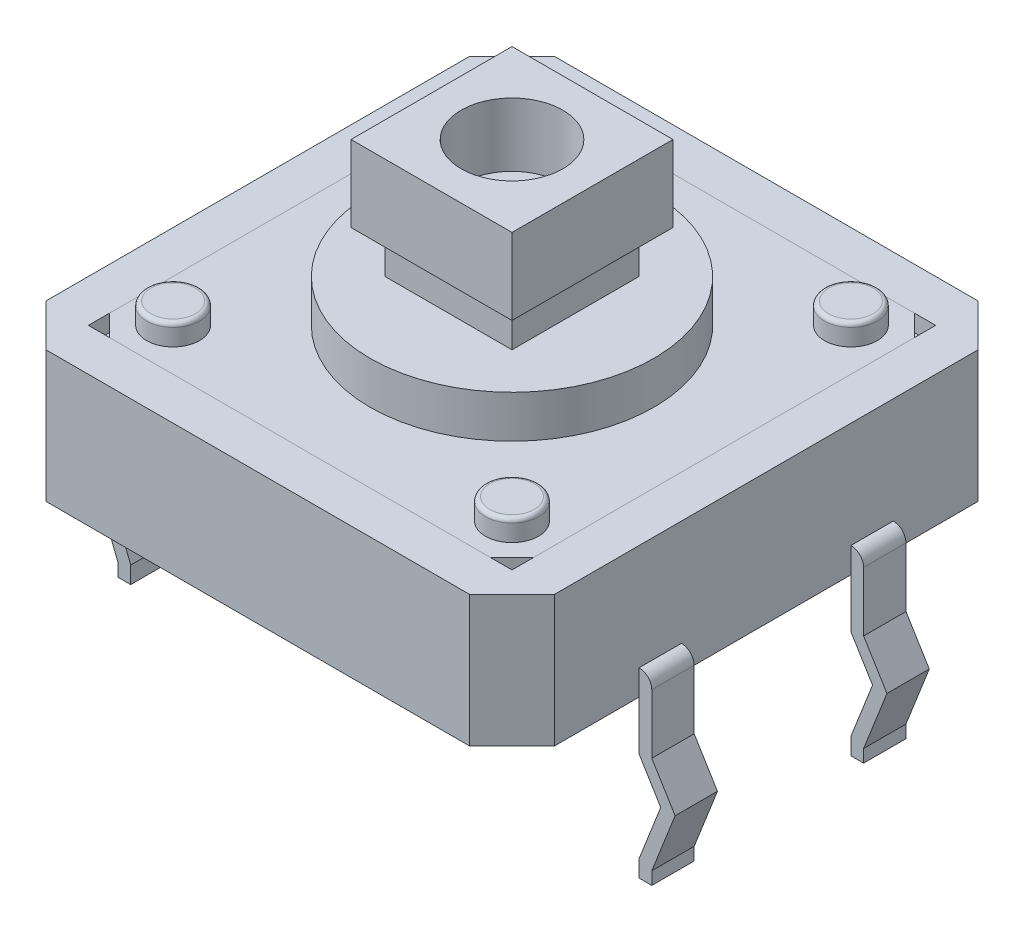
from build123d import *

# Parameters (mm, degrees)
BOSS_EXTRUDE1_DEPTH        = 3.1
SKETCH2_W                  = 10
SKETCH2_H                  = 10
CUT_EXTRUDE1_DEPTH         = 0.4
SKETCH3_R                  = 0.625
BOSS_EXTRUDE2_DEPTH        = 0.9
FILLET1_R                  = 0.1
SKETCH4_R                  = 3.35
BOSS_EXTRUDE3_DEPTH        = 0.4
BOSS_EXTRUDE4_DEPTH        = 3
BOSS_EXTRUDE4_DEPTH_BACK   = 3
BOSS_EXTRUDE4_2_DEPTH      = 3
BOSS_EXTRUDE4_2_DEPTH_BACK = 3
SKETCH6_W                  = 0.85
SKETCH6_H                  = 4
CUT_EXTRUDE2_DEPTH         = 4.6
CUT_EXTRUDE2_DEPTH_BACK    = 4.7
SKETCH7_R                  = 3.35
BOSS_EXTRUDE5_DEPTH        = 1.4
SKETCH8_W                  = 3
SKETCH8_H                  = 3
BOSS_EXTRUDE6_DEPTH        = 1
SKETCH9_W                  = 3.8
SKETCH9_H                  = 3.8
BOSS_EXTRUDE7_DEPTH        = 1.8
SKETCH11_R                 = 1.2
CUT_EXTRUDE3_DEPTH         = 1.5
BOSS_EXTRUDE8_DEPTH        = 0.2


with BuildPart() as part:
    # Sketch1 → Boss-Extrude1 (new body)
    with BuildSketch(Plane(origin=(0, 0, 0), x_dir=(1, 0, 0), z_dir=(0, 1, 0))):
        Polygon((-5, 6), (-6, 5), (-6, -5), (-5, -6), (5, -6), (6, -5), (6, 5), (5, 6), align=None)
    extrude(amount=BOSS_EXTRUDE1_DEPTH)

    # Sketch2 → Cut-Extrude1 (cut)
    with BuildSketch(Plane(origin=(0, 3.1, 0), x_dir=(1, 0, 0), z_dir=(0, 1, 0))):
        Rectangle(SKETCH2_W, SKETCH2_H)
    extrude(amount=-CUT_EXTRUDE1_DEPTH, mode=Mode.SUBTRACT)

    # Sketch3 → Boss-Extrude2 (add)
    with BuildSketch(Plane(origin=(0, 2.7, 0), x_dir=(1, 0, 0), z_dir=(0, 1, 0))):
        with Locations((-4, 4)):
            Circle(SKETCH3_R)
        with Locations((4, 4)):
            Circle(SKETCH3_R)
        with Locations((-4, -4)):
            Circle(SKETCH3_R)
        with Locations((4, -4)):
            Circle(SKETCH3_R)
    extrude(amount=BOSS_EXTRUDE2_DEPTH)

    # Fillet1
    fillet1_edges = [part.edges().sort_by_distance(p)[0] for p in [
        (-4.625, 3.6, -4),
        (3.375, 3.6, -4),
        (-4.625, 3.6, 4),
        (3.375, 3.6, 4),
    ]]
    fillet(fillet1_edges, radius=FILLET1_R)

    # Sketch12 → Boss-Extrude8 (add)
    with BuildSketch(Plane.XZ):
        Polygon((3, 5.5), (3, 3.7), (5.5, 3.7), (5.5, 4.792893219), (4.792893219, 5.5), align=None)
        Polygon((4.792893219, -5.5), (5.5, -4.792893219), (5.5, -3.7), (3, -3.7), (3, -5.5), align=None)
        Polygon((-3, -5.5), (-3, -3.7), (-5.5, -3.7), (-5.5, -4.792893219), (-4.792893219, -5.5), align=None)
        Polygon((-4.792893219, 5.5), (-5.5, 4.792893219), (-5.5, 3.7), (-3, 3.7), (-3, 5.5), align=None)
    extrude(amount=BOSS_EXTRUDE8_DEPTH)


with BuildPart() as body_2:
    # Sketch4 → Boss-Extrude3 (new body)
    with BuildSketch(Plane(origin=(0, 2.7, 0), x_dir=(1, 0, 0), z_dir=(0, 1, 0))):
        Polygon((4.5, -5), (-4.5, -5), (-5, -4.5), (-5, 4.5), (-4.5, 5), (4.5, 5), (5, 4.5), (5, -4.5), align=None)
        Circle(SKETCH4_R, mode=Mode.SUBTRACT)
    extrude(amount=BOSS_EXTRUDE3_DEPTH)


with BuildPart() as body_3:
    # Sketch5 → Boss-Extrude4 (new body, two sides)
    with BuildSketch(Plane.XY) as boss_extrude4_sk:
        with BuildLine():
            Line((6, 0.6), (6, -1.164285714))
            Line((6, -1.164285714), (6.510714286, -2))
            Line((6.510714286, -2), (6, -3.3))
            Line((6, -3.3), (6, -3.7))
            Line((6, -3.7), (6.3, -3.7))
            Line((6.3, -3.7), (6.3, -3.4))
            Line((6.3, -3.4), (6.85, -2))
            Line((6.85, -2), (6.3, -1.1))
            Line((6.3, -1.1), (6.3, 0.3))
            ThreePointArc((6.3, 0.3), (6.212132034, 0.512132034), (6, 0.6))
        make_face()
    extrude(amount=BOSS_EXTRUDE4_DEPTH)
    extrude(boss_extrude4_sk.sketch, amount=-BOSS_EXTRUDE4_DEPTH_BACK)


with BuildPart() as body_4:
    # Sketch5 → Boss-Extrude4 2 (new body, two sides)
    with BuildSketch(Plane.XY) as boss_extrude4_2_sk:
        with BuildLine():
            Line((-6.510714286, -2), (-6, -3.3))
            Line((-6, -3.3), (-6, -3.7))
            Line((-6, -3.7), (-6.3, -3.7))
            Line((-6.3, -3.7), (-6.3, -3.4))
            Line((-6.3, -3.4), (-6.85, -2))
            Line((-6.85, -2), (-6.3, -1.1))
            Line((-6.3, -1.1), (-6.3, 0.3))
            ThreePointArc((-6.3, 0.3), (-6.212132034, 0.512132034), (-6, 0.6))
            Line((-6, 0.6), (-6, -1.164285714))
            Line((-6, -1.164285714), (-6.510714286, -2))
        make_face()
    extrude(amount=BOSS_EXTRUDE4_2_DEPTH)
    extrude(boss_extrude4_2_sk.sketch, amount=-BOSS_EXTRUDE4_2_DEPTH_BACK)


with BuildPart() as cut_extrude2_tool:
    # Sketch6 → Cut-Extrude2 (new body, two sides)
    with BuildSketch(Plane(origin=(0, 0, 0), x_dir=(1, 0, 0), z_dir=(0, 1, 0))) as cut_extrude2_sk:
        with Locations((-6.425, 0)):
            Rectangle(SKETCH6_W, SKETCH6_H)
        with Locations((6.425, 0)):
            Rectangle(SKETCH6_W, SKETCH6_H)
    extrude(amount=CUT_EXTRUDE2_DEPTH)
    extrude(cut_extrude2_sk.sketch, amount=-CUT_EXTRUDE2_DEPTH_BACK)


with BuildPart() as body_3_1:
    add(body_3.part)

    # Cut-Extrude2: cut by cut_extrude2_tool
    add(cut_extrude2_tool.part, mode=Mode.SUBTRACT)


with BuildPart() as body_4_1:
    add(body_4.part)

    # Cut-Extrude2: cut by cut_extrude2_tool
    add(cut_extrude2_tool.part, mode=Mode.SUBTRACT)


with BuildPart() as body_5:
    # Sketch7 → Boss-Extrude5 (new body)
    with BuildSketch(Plane(origin=(0, 2.7, 0), x_dir=(1, 0, 0), z_dir=(0, 1, 0))):
        Circle(SKETCH7_R)
    extrude(amount=BOSS_EXTRUDE5_DEPTH)

    # Sketch8 → Boss-Extrude6 (add)
    with BuildSketch(Plane(origin=(0, 4.1, 0), x_dir=(1, 0, 0), z_dir=(0, 1, 0))):
        Rectangle(SKETCH8_W, SKETCH8_H)
    extrude(amount=BOSS_EXTRUDE6_DEPTH)

    # Sketch9 → Boss-Extrude7 (add)
    with BuildSketch(Plane(origin=(0, 5.1, 0), x_dir=(1, 0, 0), z_dir=(0, 1, 0))):
        Rectangle(SKETCH9_W, SKETCH9_H)
    extrude(amount=BOSS_EXTRUDE7_DEPTH)

    # Sketch11 → Cut-Extrude3 (cut)
    with BuildSketch(Plane(origin=(0, 6.9, 0), x_dir=(1, 0, 0), z_dir=(0, 1, 0))):
        Circle(SKETCH11_R)
    extrude(amount=-CUT_EXTRUDE3_DEPTH, mode=Mode.SUBTRACT)


solid = Compound([part.part, body_2.part, body_3_1.part, body_4_1.part, body_5.part])
